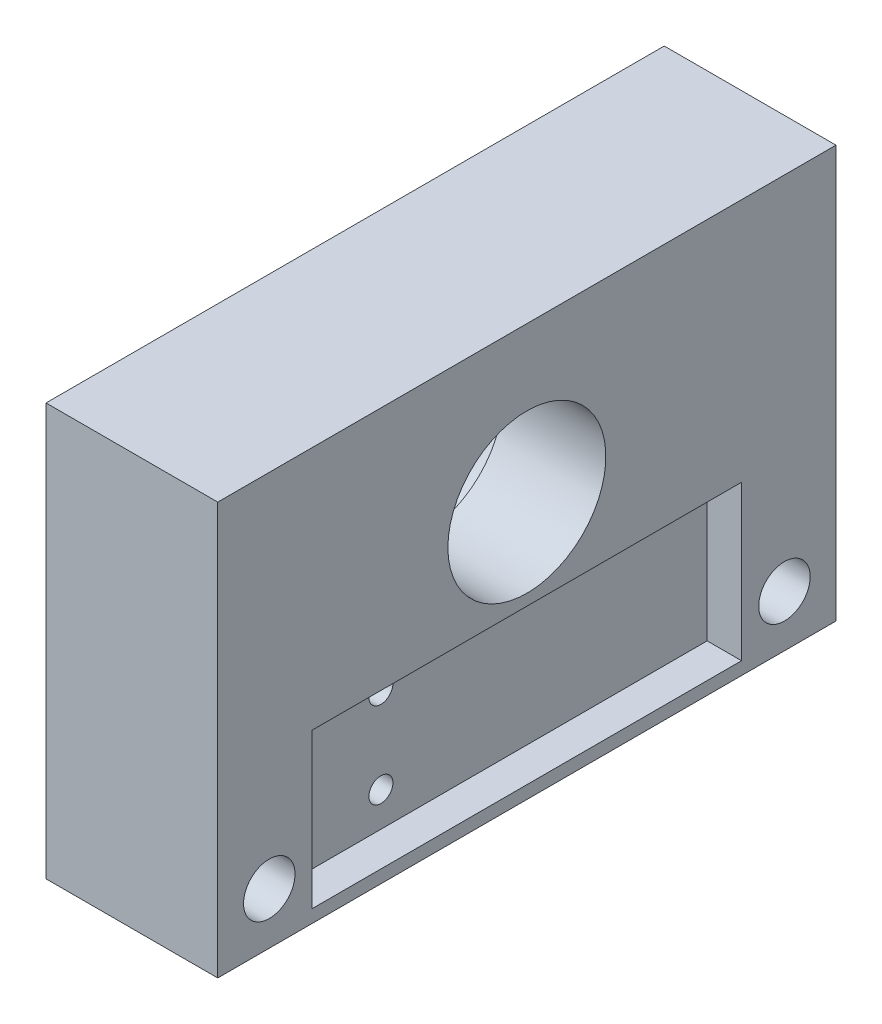
from build123d import *

# Parameters (mm, degrees)
SKETCH_1_W           = 36
SKETCH_1_H           = 24
EXTRUDE_1_DEPTH      = 10
SKETCH_2_R           = 6.05
CUT_EXTRUDE_1_DEPTH  = 4
SKETCH_3_R           = 4.6
CUT_EXTRUDE_2_DEPTH  = 7
SKETCH_5_R           = 2.5
CUT_EXTRUDE_4_DEPTH  = 8
SKETCH_7_W           = 25
SKETCH_7_H           = 9
CUT_EXTRUDE_5_DEPTH  = 2
SKETCH_8_R           = 1.5
CUT_EXTRUDE_6_DEPTH  = 5
SKETCH_9_R           = 1.5
CUT_EXTRUDE_7_DEPTH  = 5
SKETCH_11_R          = 1
CUT_EXTRUDE_9_DEPTH  = 3
SKETCH_13_R          = 0.7
CUT_EXTRUDE_10_DEPTH = 5


with BuildPart() as part:
    # 草图1 → 凸台-拉伸1 (new body)
    with BuildSketch(Plane(origin=(0, 0, 0), x_dir=(0, 0, -1), z_dir=(1, 0, 0))):
        with Locations((18, -12)):
            Rectangle(SKETCH_1_W, SKETCH_1_H)
    extrude(amount=EXTRUDE_1_DEPTH)

    # 草图2 → 切除-拉伸1 (cut)
    with BuildSketch(Plane.ZY):
        with Locations((-18, -9)):
            Circle(SKETCH_2_R)
    extrude(amount=-CUT_EXTRUDE_1_DEPTH, mode=Mode.SUBTRACT)

    # 草图3 → 切除-拉伸2 (cut, through all)
    with BuildSketch(Plane.ZY.offset(-4)):
        with Locations((-18, -9)):
            Circle(SKETCH_3_R)
    extrude(amount=-CUT_EXTRUDE_2_DEPTH, mode=Mode.SUBTRACT)

    # 草图5 → 切除-拉伸4 (cut)
    with BuildSketch(Plane(origin=(0, -24, 0), x_dir=(-1, 0, 0), z_dir=(0, -1, 0))):
        with Locations((-5, 28)):
            Circle(SKETCH_5_R)
        with Locations((-5, 8)):
            Circle(SKETCH_5_R)
    extrude(amount=-CUT_EXTRUDE_4_DEPTH, mode=Mode.SUBTRACT)

    # 草图7 → 切除-拉伸5 (cut)
    with BuildSketch(Plane(origin=(10, 0, 0), x_dir=(0, 0, -1), z_dir=(1, 0, 0))):
        with Locations((18, -18.75)):
            Rectangle(SKETCH_7_W, SKETCH_7_H)
    extrude(amount=-CUT_EXTRUDE_5_DEPTH, mode=Mode.SUBTRACT)

    # 草图8 → 切除-拉伸6 (cut)
    with BuildSketch(Plane.ZY):
        with Locations((-10, -9)):
            Circle(SKETCH_8_R)
        with Locations((-26, -9)):
            Circle(SKETCH_8_R)
    extrude(amount=-CUT_EXTRUDE_6_DEPTH, mode=Mode.SUBTRACT)

    # 草图9 → 切除-拉伸7 (cut)
    with BuildSketch(Plane(origin=(10, 0, 0), x_dir=(0, 0, -1), z_dir=(1, 0, 0))):
        with Locations((3, -21)):
            Circle(SKETCH_9_R)
        with Locations((33, -21)):
            Circle(SKETCH_9_R)
    extrude(amount=-CUT_EXTRUDE_7_DEPTH, mode=Mode.SUBTRACT)

    # 草图11 → 切除-拉伸9 (cut)
    with BuildSketch(Plane.ZY):
        with Locations((-32.5, -3)):
            Circle(SKETCH_11_R)
        with Locations((-32.5, -21)):
            Circle(SKETCH_11_R)
        with Locations((-3.5, -21)):
            Circle(SKETCH_11_R)
        with Locations((-3.5, -3)):
            Circle(SKETCH_11_R)
    extrude(amount=-CUT_EXTRUDE_9_DEPTH, mode=Mode.SUBTRACT)

    # 草图13 → 切除-拉伸10 (cut)
    with BuildSketch(Plane(origin=(8, 0, 0), x_dir=(0, 0, -1), z_dir=(1, 0, 0))):
        with Locations((11.5, -16.25)):
            Circle(SKETCH_13_R)
        with Locations((11.5, -21.25)):
            Circle(SKETCH_13_R)
    extrude(amount=-CUT_EXTRUDE_10_DEPTH, mode=Mode.SUBTRACT)


solid = part.part
